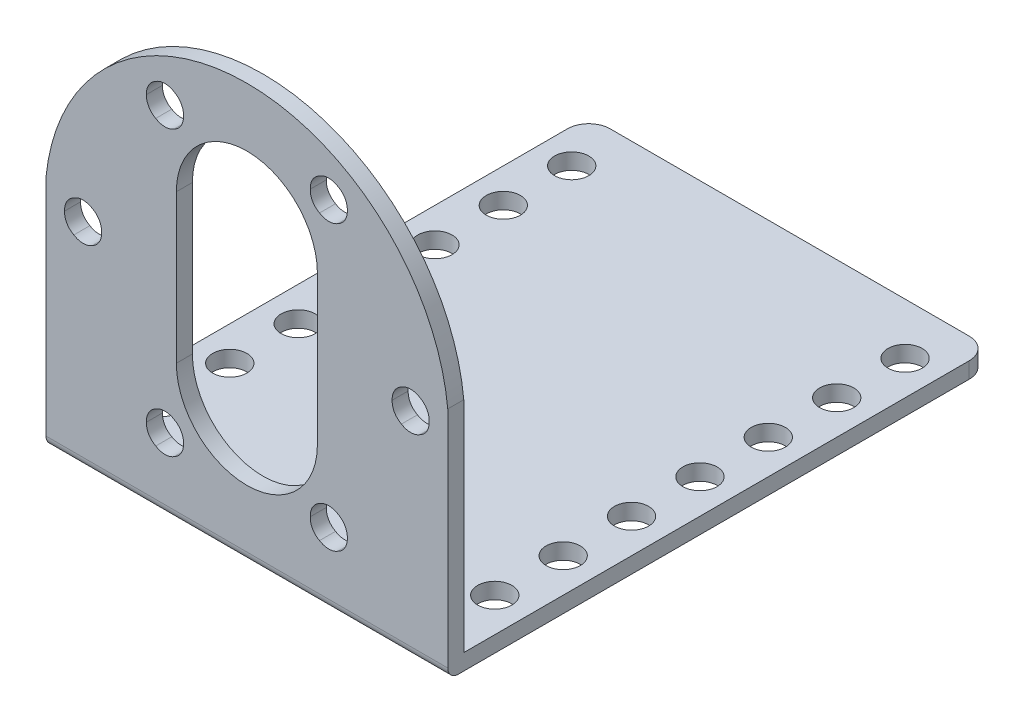
from build123d import *

# Parameters (mm, degrees)
BOSS_EXTRUDE1_DEPTH     = 1.5
SKETCH2_W               = 37.6
SKETCH2_H               = 50.8
BOSS_EXTRUDE2_DEPTH     = 1.5
FILLET1_R               = 1
FILLET2_R               = 2
SKETCH3_R               = 1.6
CUT_EXTRUDE1_DEPTH      = 1.5
LPATTERN1_COUNT         = 7
LPATTERN1_PITCH         = 6.4
MIRROR1_COPY_1_SKETCH_R = 1.6
MIRROR1_COPY_1_DEPTH    = 1.5
MIRROR1_COPY_2_SKETCH_R = 1.6
MIRROR1_COPY_2_DEPTH    = 1.5
MIRROR1_COPY_3_SKETCH_R = 1.6
MIRROR1_COPY_3_DEPTH    = 1.5
MIRROR1_COPY_4_SKETCH_R = 1.6
MIRROR1_COPY_4_DEPTH    = 1.5
MIRROR1_COPY_5_SKETCH_R = 1.6
MIRROR1_COPY_5_DEPTH    = 1.5
MIRROR1_COPY_6_SKETCH_R = 1.6
MIRROR1_COPY_6_DEPTH    = 1.5
SKETCH4_R               = 1.6
CUT_EXTRUDE2_DEPTH      = 1.5
CIRPATTERN1_COUNT       = 6


with BuildPart() as part:
    # Sketch1 → Boss-Extrude1 (new body)
    with BuildSketch(Plane.XY):
        with BuildLine():
            Line((-18.8, 0), (18.8, 0))
            Line((18.8, 0), (18.8, 22))
            ThreePointArc((18.8, 22), (0, 39), (-18.8, 22))
            Line((-18.8, 22), (-18.8, 0))
        make_face()
        with BuildLine():
            Line((-6.6, 12.999434154), (-6.6, 26.899434154))
            ThreePointArc((-6.6, 26.899434154), (0, 33.5), (6.6, 26.899434154))
            Line((6.6, 26.899434154), (6.6, 12.999434154))
            ThreePointArc((6.6, 12.999434154), (0, 6.399999946), (-6.6, 12.999434154))
        make_face(mode=Mode.SUBTRACT)
    extrude(amount=BOSS_EXTRUDE1_DEPTH)

    # Sketch2 → Boss-Extrude2 (add)
    with BuildSketch(Plane.XZ):
        with Locations((0, -23.9)):
            Rectangle(SKETCH2_W, SKETCH2_H)
    extrude(amount=-BOSS_EXTRUDE2_DEPTH)

    # Fillet1
    fillet1_edges = [part.edges().sort_by_distance(p)[0] for p in [
        (0, 0, 1.5),
    ]]
    fillet(fillet1_edges, radius=FILLET1_R)

    # Fillet2
    fillet2_edges = [part.edges().sort_by_distance(p)[0] for p in [
        (-18.8, 0.75, -49.3),
        (18.8, 0.75, -49.3),
    ]]
    fillet(fillet2_edges, radius=FILLET2_R)

    # Sketch3 → Cut-Extrude1 (cut)
    with BuildSketch(Plane.XZ):
        with Locations((-15.6, -44.5)):
            Circle(SKETCH3_R)
    cut_extrude1 = extrude(amount=-CUT_EXTRUDE1_DEPTH, mode=Mode.SUBTRACT)

    # LPattern1: Cut-Extrude1 ×7
    with Locations(*[(0, 0, i * LPATTERN1_PITCH) for i in range(1, LPATTERN1_COUNT)]):
        add(cut_extrude1, mode=Mode.SUBTRACT)

    # Mirror1: Cut-Extrude1 across plane
    add(cut_extrude1.mirror(Plane(origin=(0, 0, 0), x_dir=(0, 0, 1), z_dir=(1, 0, 0))), mode=Mode.SUBTRACT)

    # Mirror1 copy 1 sketch → Mirror1 copy 1 (cut)
    with BuildSketch(Plane(origin=(0, 0, 6.4), x_dir=(-1, 0, 0), z_dir=(0, -1, 0))):
        with Locations((-15.6, 44.5)):
            Circle(MIRROR1_COPY_1_SKETCH_R)
    extrude(amount=-MIRROR1_COPY_1_DEPTH, mode=Mode.SUBTRACT)

    # Mirror1 copy 2 sketch → Mirror1 copy 2 (cut)
    with BuildSketch(Plane(origin=(0, 0, 12.8), x_dir=(-1, 0, 0), z_dir=(0, -1, 0))):
        with Locations((-15.6, 44.5)):
            Circle(MIRROR1_COPY_2_SKETCH_R)
    extrude(amount=-MIRROR1_COPY_2_DEPTH, mode=Mode.SUBTRACT)

    # Mirror1 copy 3 sketch → Mirror1 copy 3 (cut)
    with BuildSketch(Plane(origin=(0, 0, 19.2), x_dir=(-1, 0, 0), z_dir=(0, -1, 0))):
        with Locations((-15.6, 44.5)):
            Circle(MIRROR1_COPY_3_SKETCH_R)
    extrude(amount=-MIRROR1_COPY_3_DEPTH, mode=Mode.SUBTRACT)

    # Mirror1 copy 4 sketch → Mirror1 copy 4 (cut)
    with BuildSketch(Plane(origin=(0, 0, 25.6), x_dir=(-1, 0, 0), z_dir=(0, -1, 0))):
        with Locations((-15.6, 44.5)):
            Circle(MIRROR1_COPY_4_SKETCH_R)
    extrude(amount=-MIRROR1_COPY_4_DEPTH, mode=Mode.SUBTRACT)

    # Mirror1 copy 5 sketch → Mirror1 copy 5 (cut)
    with BuildSketch(Plane(origin=(0, 0, 32), x_dir=(-1, 0, 0), z_dir=(0, -1, 0))):
        with Locations((-15.6, 44.5)):
            Circle(MIRROR1_COPY_5_SKETCH_R)
    extrude(amount=-MIRROR1_COPY_5_DEPTH, mode=Mode.SUBTRACT)

    # Mirror1 copy 6 sketch → Mirror1 copy 6 (cut)
    with BuildSketch(Plane(origin=(0, 0, 38.4), x_dir=(-1, 0, 0), z_dir=(0, -1, 0))):
        with Locations((-15.6, 44.5)):
            Circle(MIRROR1_COPY_6_SKETCH_R)
    extrude(amount=-MIRROR1_COPY_6_DEPTH, mode=Mode.SUBTRACT)

    # Sketch4 → Cut-Extrude2 (cut)
    with BuildSketch(Plane.XY.offset(1.5)):
        with Locations((7.664771385, 33.22577344)):
            Circle(SKETCH4_R)
        with Locations((15.32954277, 19.949999973)):
            Circle(SKETCH4_R)
        with Locations((7.664771385, 6.674226506)):
            Circle(SKETCH4_R)
        with Locations((-7.664771385, 6.674226506)):
            Circle(SKETCH4_R)
        with Locations((-15.32954277, 19.949999973)):
            Circle(SKETCH4_R)
        with Locations((-7.664771385, 33.22577344)):
            Circle(SKETCH4_R)
    cut_extrude2 = extrude(amount=-CUT_EXTRUDE2_DEPTH, mode=Mode.SUBTRACT)

    # CirPattern1: Cut-Extrude2 ×6 about axis
    cirpattern1_axis = Axis((0, 20.104705882, 0), (0, 0, 1))
    for i in range(1, CIRPATTERN1_COUNT):
        add(cut_extrude2.rotate(cirpattern1_axis, i * 360 / CIRPATTERN1_COUNT), mode=Mode.SUBTRACT)


solid = part.part
